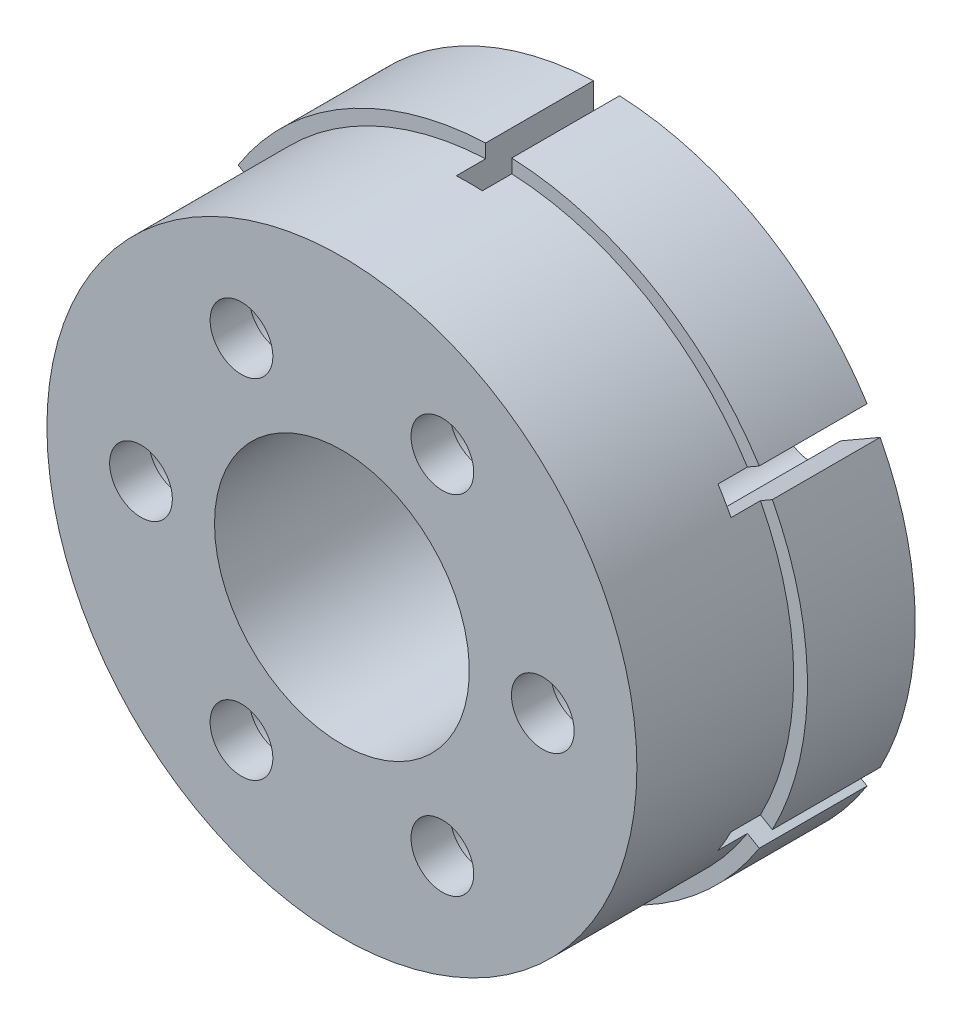
from build123d import *

# Parameters (mm, degrees)
SKETCH_1_R               = 15.75
EXTRUDE_1_DEPTH          = 5.5
SKETCH_3_R               = 15.05
EXTRUDE_2_DEPTH          = 8
SKETCH_4_R               = 1.6
CUT_EXTRUDE_2_DEPTH      = 14.5
SKETCH_5_R               = 2.15
CUT_EXTRUDE_3_DEPTH      = 11.5
SKETCH_8_R               = 3.5
CUT_EXTRUDE_7_DEPTH      = 5.5
PATTERN_CIRCULAR_2_COUNT = 6
SKETCH_6_R               = 6.5
CUT_EXTRUDE_4_DEPTH      = 14.5
SKETCH_7_R               = 7.55
CUT_EXTRUDE_5_DEPTH      = 4
SKETCH_2_R               = 1.55
CUT_EXTRUDE_6_DEPTH      = 7
SKETCH_9_W               = 1.33041347
SKETCH_9_H               = 3
CUT_EXTRUDE_8_DEPTH      = 7
PATTERN_CIRCULAR_3_COUNT = 6


with BuildPart() as part:
    # 草图1 → 凸台-拉伸1 (new body)
    with BuildSketch(Plane.XY):
        Circle(SKETCH_1_R)
    extrude(amount=EXTRUDE_1_DEPTH)

    # 草图3 → 凸台-拉伸2 (add)
    with BuildSketch(Plane.XY.offset(5.5)):
        Circle(SKETCH_3_R)
    extrude(amount=EXTRUDE_2_DEPTH)

    # 草图4 → 切除-拉伸2 (cut, through all)
    with BuildSketch(Plane(origin=(0, 0, 0), x_dir=(-1, 0, 0), z_dir=(0, 0, -1))):
        with Locations((-10.25, 0)):
            Circle(SKETCH_4_R)
    cut_extrude_2 = extrude(amount=-CUT_EXTRUDE_2_DEPTH, mode=Mode.SUBTRACT)

    # 草图5 → 切除-拉伸3 (cut)
    with BuildSketch(Plane(origin=(0, 0, 0), x_dir=(-1, 0, 0), z_dir=(0, 0, -1))):
        with Locations((-10.25, 0)):
            Circle(SKETCH_5_R)
    cut_extrude_3 = extrude(amount=-CUT_EXTRUDE_3_DEPTH, mode=Mode.SUBTRACT)

    # 草图8 → 切除-拉伸7 (cut)
    with BuildSketch(Plane(origin=(0, 0, 0), x_dir=(-1, 0, 0), z_dir=(0, 0, -1))):
        with Locations((-10.25, 0)):
            Circle(SKETCH_8_R)
    cut_extrude_7 = extrude(amount=-CUT_EXTRUDE_7_DEPTH, mode=Mode.SUBTRACT)

    # 阵列(圆周)2: 切除-拉伸2, 切除-拉伸3, 切除-拉伸7 ×6 about axis
    pattern_circular_2_axis = Axis((0, 0, 0), (0, 0, 1))
    for i in range(1, PATTERN_CIRCULAR_2_COUNT):
        add(cut_extrude_2.rotate(pattern_circular_2_axis, i * 360 / PATTERN_CIRCULAR_2_COUNT), mode=Mode.SUBTRACT)
        add(cut_extrude_3.rotate(pattern_circular_2_axis, i * 360 / PATTERN_CIRCULAR_2_COUNT), mode=Mode.SUBTRACT)
        add(cut_extrude_7.rotate(pattern_circular_2_axis, i * 360 / PATTERN_CIRCULAR_2_COUNT), mode=Mode.SUBTRACT)

    # 草图6 → 切除-拉伸4 (cut, through all)
    with BuildSketch(Plane(origin=(0, 0, 0), x_dir=(-1, 0, 0), z_dir=(0, 0, -1))):
        Circle(SKETCH_6_R)
    extrude(amount=-CUT_EXTRUDE_4_DEPTH, mode=Mode.SUBTRACT)

    # 草图7 → 切除-拉伸5 (cut)
    with BuildSketch(Plane(origin=(0, 0, 0), x_dir=(-1, 0, 0), z_dir=(0, 0, -1))):
        Circle(SKETCH_7_R)
    extrude(amount=-CUT_EXTRUDE_5_DEPTH, mode=Mode.SUBTRACT)

    # 草图2 → 切除-拉伸6 (cut)
    with BuildSketch(Plane(origin=(0, 0, 0), x_dir=(-1, 0, 0), z_dir=(0, 0, -1))):
        with Locations((0, 12)):
            Circle(SKETCH_2_R)
    cut_extrude_6 = extrude(amount=-CUT_EXTRUDE_6_DEPTH, mode=Mode.SUBTRACT)

    # 草图9 → 切除-拉伸8 (cut)
    with BuildSketch(Plane(origin=(0, 0, 0), x_dir=(-1, 0, 0), z_dir=(0, 0, -1))):
        with Locations((0, 14.9)):
            Rectangle(SKETCH_9_W, SKETCH_9_H)
    cut_extrude_8 = extrude(amount=-CUT_EXTRUDE_8_DEPTH, mode=Mode.SUBTRACT)

    # 阵列(圆周)3: 切除-拉伸6, 切除-拉伸8 ×6 about axis
    pattern_circular_3_axis = Axis((0, 0, 0), (0, 0, 1))
    for i in range(1, PATTERN_CIRCULAR_3_COUNT):
        add(cut_extrude_6.rotate(pattern_circular_3_axis, i * 360 / PATTERN_CIRCULAR_3_COUNT), mode=Mode.SUBTRACT)
        add(cut_extrude_8.rotate(pattern_circular_3_axis, i * 360 / PATTERN_CIRCULAR_3_COUNT), mode=Mode.SUBTRACT)


solid = part.part
